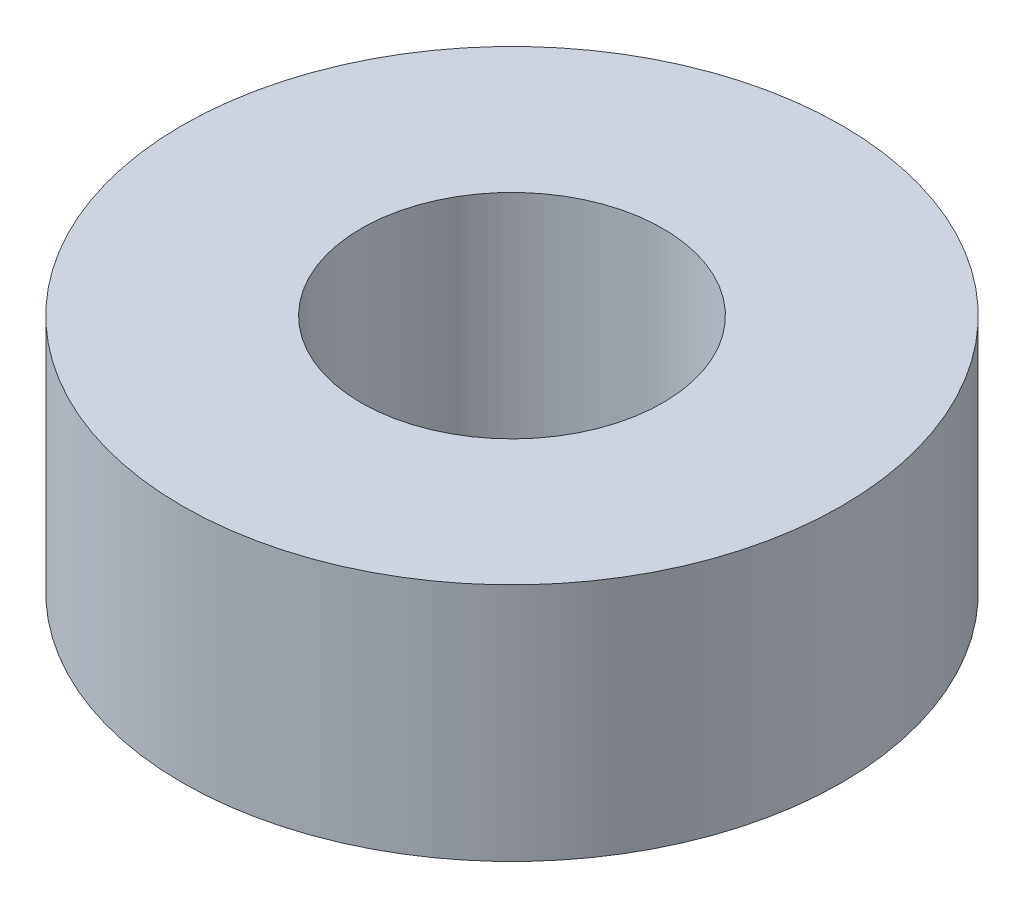
from build123d import *

# Parameters (mm, degrees)
SKETCH1_R           = 8.7376
SKETCH1_R_2         = 4.0005
BOSS_EXTRUDE1_DEPTH = 6.35


with BuildPart() as part:
    # Sketch1 → Boss-Extrude1 (new body)
    with BuildSketch(Plane(origin=(0, 0, 0), x_dir=(1, 0, 0), z_dir=(0, 1, 0))):
        Circle(SKETCH1_R)
        Circle(SKETCH1_R_2, mode=Mode.SUBTRACT)
    extrude(amount=BOSS_EXTRUDE1_DEPTH)


solid = part.part
